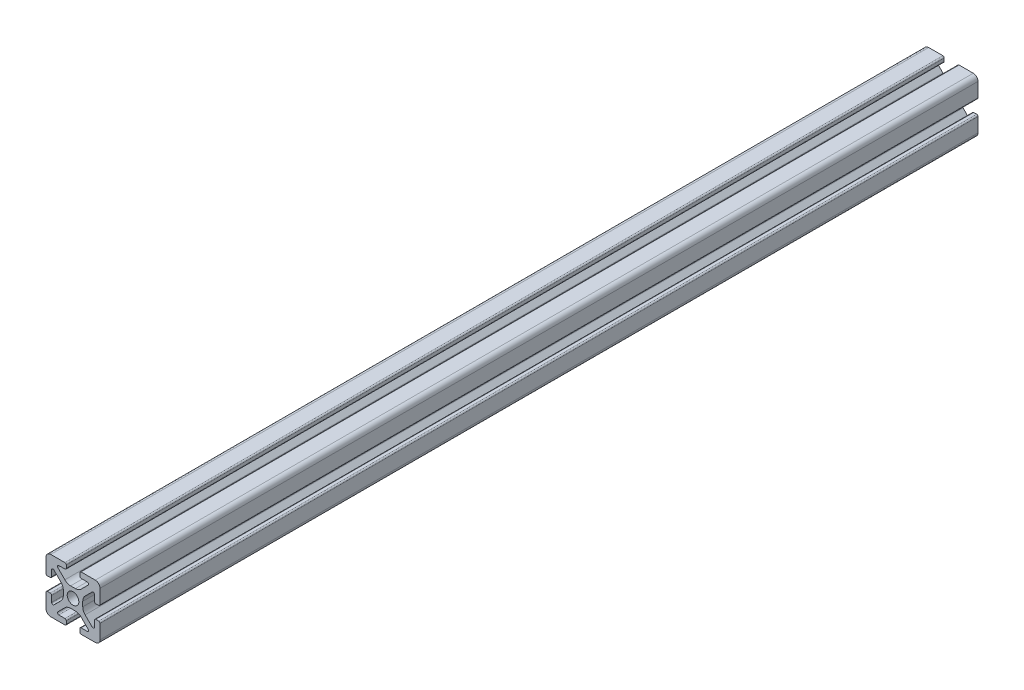
from build123d import *

# Parameters (mm, degrees)
BOSS_EXTRUDE1_DEPTH = 162.5


with BuildPart() as part:
    # Sketch4 → Boss-Extrude1 (new body, symmetric)
    with BuildSketch(Plane.XY):
        with BuildLine():
            Line((3, -10), (8.25, -10))
            ThreePointArc((8.25, -10), (9.487436867, -9.487436867), (10, -8.25))
            Line((10, -8.25), (10, -3))
            ThreePointArc((10, -3), (9.853553391, -2.646446609), (9.5, -2.5))
            Line((9.5, -2.5), (8.424621202, -2.5))
            ThreePointArc((8.424621202, -2.5), (8.071067812, -2.646446609), (7.924621202, -3))
            Line((7.924621202, -3), (7.924621202, -5.25))
            ThreePointArc((7.924621202, -5.25), (7.615962919, -5.711939766), (7.071067812, -5.603553391))
            Line((7.071067812, -5.603553391), (4.478679656, -3.011165235))
            ThreePointArc((4.478679656, -3.011165235), (3.828361402, -2.037895189), (3.6, -0.889844892))
            Line((3.6, -0.889844892), (3.6, 0))
            Line((3.6, 0), (2.15, 0))
            ThreePointArc((2.15, 0), (1.52027958, -1.52027958), (0, -2.15))
            Line((0, -2.15), (0, -3.6))
            Line((0, -3.6), (0.889844892, -3.6))
            ThreePointArc((0.889844892, -3.6), (2.037895189, -3.828361402), (3.011165235, -4.478679656))
            Line((3.011165235, -4.478679656), (5.603553391, -7.071067812))
            ThreePointArc((5.603553391, -7.071067812), (5.711939766, -7.615962919), (5.25, -7.924621202))
            Line((5.25, -7.924621202), (3, -7.924621202))
            ThreePointArc((3, -7.924621202), (2.646446609, -8.071067812), (2.5, -8.424621202))
            Line((2.5, -8.424621202), (2.5, -9.5))
            ThreePointArc((2.5, -9.5), (2.646446609, -9.853553391), (3, -10))
        make_face()
    extrude(amount=BOSS_EXTRUDE1_DEPTH, both=True)

    # Mirror1: part across plane


with BuildPart() as part_1:
    add(part.part)
    add(part.part.mirror(Plane(origin=(0, 0, 0), x_dir=(0, 0, 1), z_dir=(1, 0, 0))))

    # Mirror2: part across plane


with BuildPart() as part_2:
    add(part_1.part)
    add(part_1.part.mirror(Plane.ZX))


solid = part_2.part
